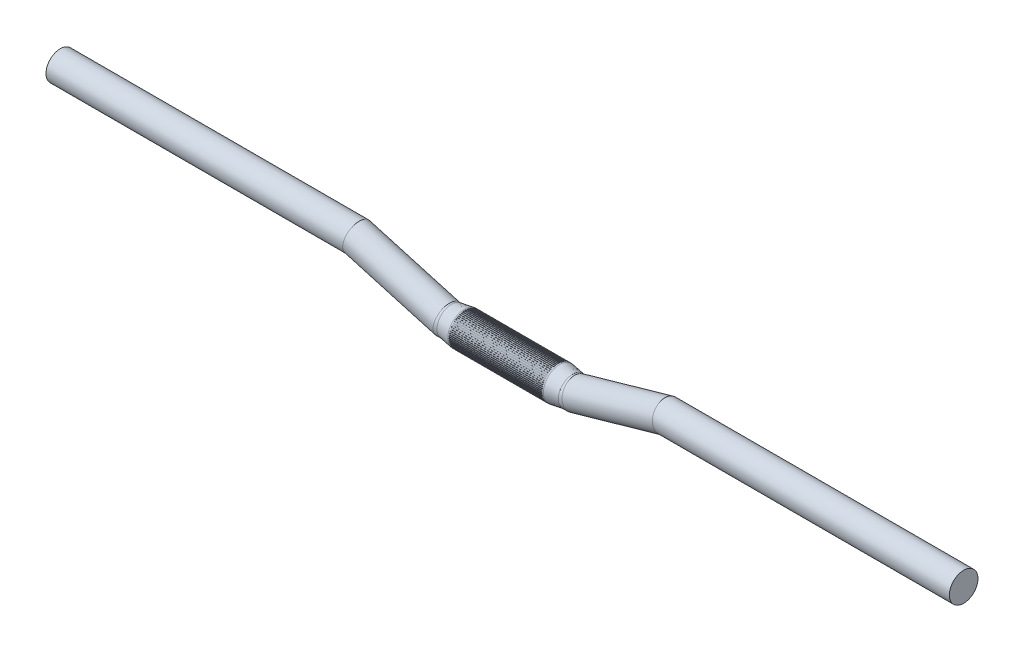
from build123d import *

# Parameters (mm, degrees)
ESQUISSE2_R                  = 11.1
ESQUISSE4_R                  = 12.7
BOSS_EXTRU_1_DEPTH           = 47
ESQUISSE5_W                  = 0.5
ESQUISSE5_H                  = 0.5
ENL_V_MAT_EXTRU_1_DEPTH      = 36
R_P_TITION_CIRCULAIRE1_COUNT = 68
SYM_TRIE1_COPY_1_SKETCH_W    = 0.5
SYM_TRIE1_COPY_1_SKETCH_H    = 0.5
SYM_TRIE1_COPY_1_DEPTH       = 36
SYM_TRIE1_COPY_2_SKETCH_W    = 0.5
SYM_TRIE1_COPY_2_SKETCH_H    = 0.5
SYM_TRIE1_COPY_2_DEPTH       = 36
SYM_TRIE1_COPY_3_SKETCH_W    = 0.5
SYM_TRIE1_COPY_3_SKETCH_H    = 0.5
SYM_TRIE1_COPY_3_DEPTH       = 36
SYM_TRIE1_COPY_4_SKETCH_W    = 0.5
SYM_TRIE1_COPY_4_SKETCH_H    = 0.5
SYM_TRIE1_COPY_4_DEPTH       = 36
SYM_TRIE1_COPY_5_SKETCH_W    = 0.5
SYM_TRIE1_COPY_5_SKETCH_H    = 0.5
SYM_TRIE1_COPY_5_DEPTH       = 36
SYM_TRIE1_COPY_6_SKETCH_W    = 0.5
SYM_TRIE1_COPY_6_SKETCH_H    = 0.5
SYM_TRIE1_COPY_6_DEPTH       = 36
SYM_TRIE1_COPY_7_SKETCH_W    = 0.5
SYM_TRIE1_COPY_7_SKETCH_H    = 0.5
SYM_TRIE1_COPY_7_DEPTH       = 36
SYM_TRIE1_COPY_8_SKETCH_W    = 0.5
SYM_TRIE1_COPY_8_SKETCH_H    = 0.5
SYM_TRIE1_COPY_8_DEPTH       = 36
SYM_TRIE1_COPY_9_SKETCH_W    = 0.5
SYM_TRIE1_COPY_9_SKETCH_H    = 0.5
SYM_TRIE1_COPY_9_DEPTH       = 36
SYM_TRIE1_COPY_10_SKETCH_W   = 0.5
SYM_TRIE1_COPY_10_SKETCH_H   = 0.5
SYM_TRIE1_COPY_10_DEPTH      = 36
SYM_TRIE1_COPY_11_SKETCH_W   = 0.5
SYM_TRIE1_COPY_11_SKETCH_H   = 0.5
SYM_TRIE1_COPY_11_DEPTH      = 36
SYM_TRIE1_COPY_12_SKETCH_W   = 0.5
SYM_TRIE1_COPY_12_SKETCH_H   = 0.5
SYM_TRIE1_COPY_12_DEPTH      = 36
SYM_TRIE1_COPY_13_SKETCH_W   = 0.5
SYM_TRIE1_COPY_13_SKETCH_H   = 0.5
SYM_TRIE1_COPY_13_DEPTH      = 36
SYM_TRIE1_COPY_14_SKETCH_W   = 0.5
SYM_TRIE1_COPY_14_SKETCH_H   = 0.5
SYM_TRIE1_COPY_14_DEPTH      = 36
SYM_TRIE1_COPY_15_SKETCH_W   = 0.5
SYM_TRIE1_COPY_15_SKETCH_H   = 0.5
SYM_TRIE1_COPY_15_DEPTH      = 36
SYM_TRIE1_COPY_16_SKETCH_W   = 0.5
SYM_TRIE1_COPY_16_SKETCH_H   = 0.5
SYM_TRIE1_COPY_16_DEPTH      = 36
SYM_TRIE1_COPY_17_SKETCH_W   = 0.5
SYM_TRIE1_COPY_17_SKETCH_H   = 0.5
SYM_TRIE1_COPY_17_DEPTH      = 36
SYM_TRIE1_COPY_18_SKETCH_W   = 0.5
SYM_TRIE1_COPY_18_SKETCH_H   = 0.5
SYM_TRIE1_COPY_18_DEPTH      = 36
SYM_TRIE1_COPY_19_SKETCH_W   = 0.5
SYM_TRIE1_COPY_19_SKETCH_H   = 0.5
SYM_TRIE1_COPY_19_DEPTH      = 36
SYM_TRIE1_COPY_20_SKETCH_W   = 0.5
SYM_TRIE1_COPY_20_SKETCH_H   = 0.5
SYM_TRIE1_COPY_20_DEPTH      = 36
SYM_TRIE1_COPY_21_SKETCH_W   = 0.5
SYM_TRIE1_COPY_21_SKETCH_H   = 0.5
SYM_TRIE1_COPY_21_DEPTH      = 36
SYM_TRIE1_COPY_22_SKETCH_W   = 0.5
SYM_TRIE1_COPY_22_SKETCH_H   = 0.5
SYM_TRIE1_COPY_22_DEPTH      = 36
SYM_TRIE1_COPY_23_SKETCH_W   = 0.5
SYM_TRIE1_COPY_23_SKETCH_H   = 0.5
SYM_TRIE1_COPY_23_DEPTH      = 36
SYM_TRIE1_COPY_24_SKETCH_W   = 0.5
SYM_TRIE1_COPY_24_SKETCH_H   = 0.5
SYM_TRIE1_COPY_24_DEPTH      = 36
SYM_TRIE1_COPY_25_SKETCH_W   = 0.5
SYM_TRIE1_COPY_25_SKETCH_H   = 0.5
SYM_TRIE1_COPY_25_DEPTH      = 36
SYM_TRIE1_COPY_26_SKETCH_W   = 0.5
SYM_TRIE1_COPY_26_SKETCH_H   = 0.5
SYM_TRIE1_COPY_26_DEPTH      = 36
SYM_TRIE1_COPY_27_SKETCH_W   = 0.5
SYM_TRIE1_COPY_27_SKETCH_H   = 0.5
SYM_TRIE1_COPY_27_DEPTH      = 36
SYM_TRIE1_COPY_28_SKETCH_W   = 0.5
SYM_TRIE1_COPY_28_SKETCH_H   = 0.5
SYM_TRIE1_COPY_28_DEPTH      = 36
SYM_TRIE1_COPY_29_SKETCH_W   = 0.5
SYM_TRIE1_COPY_29_SKETCH_H   = 0.5
SYM_TRIE1_COPY_29_DEPTH      = 36
SYM_TRIE1_COPY_30_SKETCH_W   = 0.5
SYM_TRIE1_COPY_30_SKETCH_H   = 0.5
SYM_TRIE1_COPY_30_DEPTH      = 36
SYM_TRIE1_COPY_31_SKETCH_W   = 0.5
SYM_TRIE1_COPY_31_SKETCH_H   = 0.5
SYM_TRIE1_COPY_31_DEPTH      = 36
SYM_TRIE1_COPY_32_SKETCH_W   = 0.5
SYM_TRIE1_COPY_32_SKETCH_H   = 0.5
SYM_TRIE1_COPY_32_DEPTH      = 36
SYM_TRIE1_COPY_33_SKETCH_W   = 0.5
SYM_TRIE1_COPY_33_SKETCH_H   = 0.5
SYM_TRIE1_COPY_33_DEPTH      = 36
SYM_TRIE1_COPY_34_SKETCH_W   = 0.5
SYM_TRIE1_COPY_34_SKETCH_H   = 0.5
SYM_TRIE1_COPY_34_DEPTH      = 36
SYM_TRIE1_COPY_35_SKETCH_W   = 0.5
SYM_TRIE1_COPY_35_SKETCH_H   = 0.5
SYM_TRIE1_COPY_35_DEPTH      = 36
SYM_TRIE1_COPY_36_SKETCH_W   = 0.5
SYM_TRIE1_COPY_36_SKETCH_H   = 0.5
SYM_TRIE1_COPY_36_DEPTH      = 36
SYM_TRIE1_COPY_37_SKETCH_W   = 0.5
SYM_TRIE1_COPY_37_SKETCH_H   = 0.5
SYM_TRIE1_COPY_37_DEPTH      = 36
SYM_TRIE1_COPY_38_SKETCH_W   = 0.5
SYM_TRIE1_COPY_38_SKETCH_H   = 0.5
SYM_TRIE1_COPY_38_DEPTH      = 36
SYM_TRIE1_COPY_39_SKETCH_W   = 0.5
SYM_TRIE1_COPY_39_SKETCH_H   = 0.5
SYM_TRIE1_COPY_39_DEPTH      = 36
SYM_TRIE1_COPY_40_SKETCH_W   = 0.5
SYM_TRIE1_COPY_40_SKETCH_H   = 0.5
SYM_TRIE1_COPY_40_DEPTH      = 36
SYM_TRIE1_COPY_41_SKETCH_W   = 0.5
SYM_TRIE1_COPY_41_SKETCH_H   = 0.5
SYM_TRIE1_COPY_41_DEPTH      = 36
SYM_TRIE1_COPY_42_SKETCH_W   = 0.5
SYM_TRIE1_COPY_42_SKETCH_H   = 0.5
SYM_TRIE1_COPY_42_DEPTH      = 36
SYM_TRIE1_COPY_43_SKETCH_W   = 0.5
SYM_TRIE1_COPY_43_SKETCH_H   = 0.5
SYM_TRIE1_COPY_43_DEPTH      = 36
SYM_TRIE1_COPY_44_SKETCH_W   = 0.5
SYM_TRIE1_COPY_44_SKETCH_H   = 0.5
SYM_TRIE1_COPY_44_DEPTH      = 36
SYM_TRIE1_COPY_45_SKETCH_W   = 0.5
SYM_TRIE1_COPY_45_SKETCH_H   = 0.5
SYM_TRIE1_COPY_45_DEPTH      = 36
SYM_TRIE1_COPY_46_SKETCH_W   = 0.5
SYM_TRIE1_COPY_46_SKETCH_H   = 0.5
SYM_TRIE1_COPY_46_DEPTH      = 36
SYM_TRIE1_COPY_47_SKETCH_W   = 0.5
SYM_TRIE1_COPY_47_SKETCH_H   = 0.5
SYM_TRIE1_COPY_47_DEPTH      = 36
SYM_TRIE1_COPY_48_SKETCH_W   = 0.5
SYM_TRIE1_COPY_48_SKETCH_H   = 0.5
SYM_TRIE1_COPY_48_DEPTH      = 36
SYM_TRIE1_COPY_49_SKETCH_W   = 0.5
SYM_TRIE1_COPY_49_SKETCH_H   = 0.5
SYM_TRIE1_COPY_49_DEPTH      = 36
SYM_TRIE1_COPY_50_SKETCH_W   = 0.5
SYM_TRIE1_COPY_50_SKETCH_H   = 0.5
SYM_TRIE1_COPY_50_DEPTH      = 36
SYM_TRIE1_COPY_51_SKETCH_W   = 0.5
SYM_TRIE1_COPY_51_SKETCH_H   = 0.5
SYM_TRIE1_COPY_51_DEPTH      = 36
SYM_TRIE1_COPY_52_SKETCH_W   = 0.5
SYM_TRIE1_COPY_52_SKETCH_H   = 0.5
SYM_TRIE1_COPY_52_DEPTH      = 36
SYM_TRIE1_COPY_53_SKETCH_W   = 0.5
SYM_TRIE1_COPY_53_SKETCH_H   = 0.5
SYM_TRIE1_COPY_53_DEPTH      = 36
SYM_TRIE1_COPY_54_SKETCH_W   = 0.5
SYM_TRIE1_COPY_54_SKETCH_H   = 0.5
SYM_TRIE1_COPY_54_DEPTH      = 36
SYM_TRIE1_COPY_55_SKETCH_W   = 0.5
SYM_TRIE1_COPY_55_SKETCH_H   = 0.5
SYM_TRIE1_COPY_55_DEPTH      = 36
SYM_TRIE1_COPY_56_SKETCH_W   = 0.5
SYM_TRIE1_COPY_56_SKETCH_H   = 0.5
SYM_TRIE1_COPY_56_DEPTH      = 36
SYM_TRIE1_COPY_57_SKETCH_W   = 0.5
SYM_TRIE1_COPY_57_SKETCH_H   = 0.5
SYM_TRIE1_COPY_57_DEPTH      = 36
SYM_TRIE1_COPY_58_SKETCH_W   = 0.5
SYM_TRIE1_COPY_58_SKETCH_H   = 0.5
SYM_TRIE1_COPY_58_DEPTH      = 36
SYM_TRIE1_COPY_59_SKETCH_W   = 0.5
SYM_TRIE1_COPY_59_SKETCH_H   = 0.5
SYM_TRIE1_COPY_59_DEPTH      = 36
SYM_TRIE1_COPY_60_SKETCH_W   = 0.5
SYM_TRIE1_COPY_60_SKETCH_H   = 0.5
SYM_TRIE1_COPY_60_DEPTH      = 36
SYM_TRIE1_COPY_61_SKETCH_W   = 0.5
SYM_TRIE1_COPY_61_SKETCH_H   = 0.5
SYM_TRIE1_COPY_61_DEPTH      = 36
SYM_TRIE1_COPY_62_SKETCH_W   = 0.5
SYM_TRIE1_COPY_62_SKETCH_H   = 0.5
SYM_TRIE1_COPY_62_DEPTH      = 36
SYM_TRIE1_COPY_63_SKETCH_W   = 0.5
SYM_TRIE1_COPY_63_SKETCH_H   = 0.5
SYM_TRIE1_COPY_63_DEPTH      = 36
SYM_TRIE1_COPY_64_SKETCH_W   = 0.5
SYM_TRIE1_COPY_64_SKETCH_H   = 0.5
SYM_TRIE1_COPY_64_DEPTH      = 36
SYM_TRIE1_COPY_65_SKETCH_W   = 0.5
SYM_TRIE1_COPY_65_SKETCH_H   = 0.5
SYM_TRIE1_COPY_65_DEPTH      = 36
SYM_TRIE1_COPY_66_SKETCH_W   = 0.5
SYM_TRIE1_COPY_66_SKETCH_H   = 0.5
SYM_TRIE1_COPY_66_DEPTH      = 36
SYM_TRIE1_COPY_67_SKETCH_W   = 0.5
SYM_TRIE1_COPY_67_SKETCH_H   = 0.5
SYM_TRIE1_COPY_67_DEPTH      = 36
CHANFREIN3_SIZE2             = 1.583844403
CHANFREIN3_SIZE              = 10


with BuildPart() as part:
    # Balayage1: sweep along a path in Esquisse1
    with BuildLine(Plane.XY) as balayage1_path:
        Line((0, 0), (50, 0))
        Line((50, 0), (120, 20))
        Line((120, 20), (350, 20))
    # Esquisse2 → Balayage1 (sweep)
    with BuildSketch(Plane(origin=(0, 0, 0), x_dir=(0, 0, -1), z_dir=(1, 0, 0))):
        Circle(ESQUISSE2_R)
    balayage1 = sweep(path=balayage1_path.line, transition=Transition.RIGHT)

    # Esquisse4 → Boss.-Extru.1 (add)
    with BuildSketch(Plane.ZY):
        Circle(ESQUISSE4_R)
    boss_extru_1 = extrude(amount=-BOSS_EXTRU_1_DEPTH)

    # Esquisse5 → Enlèv. mat.-Extru.1 (cut)
    with BuildSketch(Plane.ZY):
        with Locations((12.7, 0)):
            Rectangle(ESQUISSE5_W, ESQUISSE5_H)
    enl_v_mat_extru_1 = extrude(amount=-ENL_V_MAT_EXTRU_1_DEPTH, mode=Mode.SUBTRACT)

    # Répétition circulaire1: Enlèv. mat.-Extru.1 ×68 about axis
    r_p_tition_circulaire1_axis = Axis((0, 0, 0), (-1, 0, 0))
    for i in range(1, R_P_TITION_CIRCULAIRE1_COUNT):
        add(enl_v_mat_extru_1.rotate(r_p_tition_circulaire1_axis, i * 360 / R_P_TITION_CIRCULAIRE1_COUNT), mode=Mode.SUBTRACT)

    # Symétrie1: Balayage1, Boss.-Extru.1, Enlèv. mat.-Extru.1 across Right Plane
    add(balayage1.mirror(Plane(origin=(0, 0, 0), x_dir=(0, 0, -1), z_dir=(1, 0, 0))))
    add(boss_extru_1.mirror(Plane(origin=(0, 0, 0), x_dir=(0, 0, -1), z_dir=(1, 0, 0))))
    add(enl_v_mat_extru_1.mirror(Plane(origin=(0, 0, 0), x_dir=(0, 0, -1), z_dir=(1, 0, 0))), mode=Mode.SUBTRACT)

    # Symétrie1 copy 1 sketch → Symétrie1 copy 1 (cut)
    with BuildSketch(Plane(origin=(0, 0, 0), x_dir=(0, 0.09226835946330199, 0.9957341762950345), z_dir=(1, 0, 0))):
        with Locations((12.7, 0)):
            Rectangle(SYM_TRIE1_COPY_1_SKETCH_W, SYM_TRIE1_COPY_1_SKETCH_H)
    extrude(amount=-SYM_TRIE1_COPY_1_DEPTH, mode=Mode.SUBTRACT)

    # Symétrie1 copy 2 sketch → Symétrie1 copy 2 (cut)
    with BuildSketch(Plane(origin=(0, 0, 0), x_dir=(0, 0.18374951781657034, 0.9829730996839018), z_dir=(1, 0, 0))):
        with Locations((12.7, 0)):
            Rectangle(SYM_TRIE1_COPY_2_SKETCH_W, SYM_TRIE1_COPY_2_SKETCH_H)
    extrude(amount=-SYM_TRIE1_COPY_2_DEPTH, mode=Mode.SUBTRACT)

    # Symétrie1 copy 3 sketch → Symétrie1 copy 3 (cut)
    with BuildSketch(Plane(origin=(0, 0, 0), x_dir=(0, 0.27366299007208283, 0.961825643172819), z_dir=(1, 0, 0))):
        with Locations((12.7, 0)):
            Rectangle(SYM_TRIE1_COPY_3_SKETCH_W, SYM_TRIE1_COPY_3_SKETCH_H)
    extrude(amount=-SYM_TRIE1_COPY_3_DEPTH, mode=Mode.SUBTRACT)

    # Symétrie1 copy 4 sketch → Symétrie1 copy 4 (cut)
    with BuildSketch(Plane(origin=(0, 0, 0), x_dir=(0, 0.3612416661871529, 0.9324722294043558), z_dir=(1, 0, 0))):
        with Locations((12.7, 0)):
            Rectangle(SYM_TRIE1_COPY_4_SKETCH_W, SYM_TRIE1_COPY_4_SKETCH_H)
    extrude(amount=-SYM_TRIE1_COPY_4_DEPTH, mode=Mode.SUBTRACT)

    # Symétrie1 copy 5 sketch → Symétrie1 copy 5 (cut)
    with BuildSketch(Plane(origin=(0, 0, 0), x_dir=(0, 0.4457383557765382, 0.8951632913550623), z_dir=(1, 0, 0))):
        with Locations((12.7, 0)):
            Rectangle(SYM_TRIE1_COPY_5_SKETCH_W, SYM_TRIE1_COPY_5_SKETCH_H)
    extrude(amount=-SYM_TRIE1_COPY_5_DEPTH, mode=Mode.SUBTRACT)

    # Symétrie1 copy 6 sketch → Symétrie1 copy 6 (cut)
    with BuildSketch(Plane(origin=(0, 0, 0), x_dir=(0, 0.5264321628773557, 0.8502171357296142), z_dir=(1, 0, 0))):
        with Locations((12.7, 0)):
            Rectangle(SYM_TRIE1_COPY_6_SKETCH_W, SYM_TRIE1_COPY_6_SKETCH_H)
    extrude(amount=-SYM_TRIE1_COPY_6_DEPTH, mode=Mode.SUBTRACT)

    # Symétrie1 copy 7 sketch → Symétrie1 copy 7 (cut)
    with BuildSketch(Plane(origin=(0, 0, 0), x_dir=(0, 0.6026346363792563, 0.7980172272802396), z_dir=(1, 0, 0))):
        with Locations((12.7, 0)):
            Rectangle(SYM_TRIE1_COPY_7_SKETCH_W, SYM_TRIE1_COPY_7_SKETCH_H)
    extrude(amount=-SYM_TRIE1_COPY_7_DEPTH, mode=Mode.SUBTRACT)

    # Symétrie1 copy 8 sketch → Symétrie1 copy 8 (cut)
    with BuildSketch(Plane(origin=(0, 0, 0), x_dir=(0, 0.6736956436465572, 0.7390089172206591), z_dir=(1, 0, 0))):
        with Locations((12.7, 0)):
            Rectangle(SYM_TRIE1_COPY_8_SKETCH_W, SYM_TRIE1_COPY_8_SKETCH_H)
    extrude(amount=-SYM_TRIE1_COPY_8_DEPTH, mode=Mode.SUBTRACT)

    # Symétrie1 copy 9 sketch → Symétrie1 copy 9 (cut)
    with BuildSketch(Plane(origin=(0, 0, 0), x_dir=(0, 0.7390089172206592, 0.6736956436465572), z_dir=(1, 0, 0))):
        with Locations((12.7, 0)):
            Rectangle(SYM_TRIE1_COPY_9_SKETCH_W, SYM_TRIE1_COPY_9_SKETCH_H)
    extrude(amount=-SYM_TRIE1_COPY_9_DEPTH, mode=Mode.SUBTRACT)

    # Symétrie1 copy 10 sketch → Symétrie1 copy 10 (cut)
    with BuildSketch(Plane(origin=(0, 0, 0), x_dir=(0, 0.7980172272802395, 0.6026346363792565), z_dir=(1, 0, 0))):
        with Locations((12.7, 0)):
            Rectangle(SYM_TRIE1_COPY_10_SKETCH_W, SYM_TRIE1_COPY_10_SKETCH_H)
    extrude(amount=-SYM_TRIE1_COPY_10_DEPTH, mode=Mode.SUBTRACT)

    # Symétrie1 copy 11 sketch → Symétrie1 copy 11 (cut)
    with BuildSketch(Plane(origin=(0, 0, 0), x_dir=(0, 0.8502171357296141, 0.5264321628773558), z_dir=(1, 0, 0))):
        with Locations((12.7, 0)):
            Rectangle(SYM_TRIE1_COPY_11_SKETCH_W, SYM_TRIE1_COPY_11_SKETCH_H)
    extrude(amount=-SYM_TRIE1_COPY_11_DEPTH, mode=Mode.SUBTRACT)

    # Symétrie1 copy 12 sketch → Symétrie1 copy 12 (cut)
    with BuildSketch(Plane(origin=(0, 0, 0), x_dir=(0, 0.8951632913550623, 0.4457383557765383), z_dir=(1, 0, 0))):
        with Locations((12.7, 0)):
            Rectangle(SYM_TRIE1_COPY_12_SKETCH_W, SYM_TRIE1_COPY_12_SKETCH_H)
    extrude(amount=-SYM_TRIE1_COPY_12_DEPTH, mode=Mode.SUBTRACT)

    # Symétrie1 copy 13 sketch → Symétrie1 copy 13 (cut)
    with BuildSketch(Plane(origin=(0, 0, 0), x_dir=(0, 0.9324722294043558, 0.36124166618715287), z_dir=(1, 0, 0))):
        with Locations((12.7, 0)):
            Rectangle(SYM_TRIE1_COPY_13_SKETCH_W, SYM_TRIE1_COPY_13_SKETCH_H)
    extrude(amount=-SYM_TRIE1_COPY_13_DEPTH, mode=Mode.SUBTRACT)

    # Symétrie1 copy 14 sketch → Symétrie1 copy 14 (cut)
    with BuildSketch(Plane(origin=(0, 0, 0), x_dir=(0, 0.961825643172819, 0.273662990072083), z_dir=(1, 0, 0))):
        with Locations((12.7, 0)):
            Rectangle(SYM_TRIE1_COPY_14_SKETCH_W, SYM_TRIE1_COPY_14_SKETCH_H)
    extrude(amount=-SYM_TRIE1_COPY_14_DEPTH, mode=Mode.SUBTRACT)

    # Symétrie1 copy 15 sketch → Symétrie1 copy 15 (cut)
    with BuildSketch(Plane(origin=(0, 0, 0), x_dir=(0, 0.9829730996839018, 0.18374951781657053), z_dir=(1, 0, 0))):
        with Locations((12.7, 0)):
            Rectangle(SYM_TRIE1_COPY_15_SKETCH_W, SYM_TRIE1_COPY_15_SKETCH_H)
    extrude(amount=-SYM_TRIE1_COPY_15_DEPTH, mode=Mode.SUBTRACT)

    # Symétrie1 copy 16 sketch → Symétrie1 copy 16 (cut)
    with BuildSketch(Plane(origin=(0, 0, 0), x_dir=(0, 0.9957341762950345, 0.09226835946330202), z_dir=(1, 0, 0))):
        with Locations((12.7, 0)):
            Rectangle(SYM_TRIE1_COPY_16_SKETCH_W, SYM_TRIE1_COPY_16_SKETCH_H)
    extrude(amount=-SYM_TRIE1_COPY_16_DEPTH, mode=Mode.SUBTRACT)

    # Symétrie1 copy 17 sketch → Symétrie1 copy 17 (cut)
    with BuildSketch(Plane.YZ):
        with Locations((12.7, 0)):
            Rectangle(SYM_TRIE1_COPY_17_SKETCH_W, SYM_TRIE1_COPY_17_SKETCH_H)
    extrude(amount=-SYM_TRIE1_COPY_17_DEPTH, mode=Mode.SUBTRACT)

    # Symétrie1 copy 18 sketch → Symétrie1 copy 18 (cut)
    with BuildSketch(Plane(origin=(0, 0, 0), x_dir=(0, 0.9957341762950345, -0.09226835946330211), z_dir=(1, 0, 0))):
        with Locations((12.7, 0)):
            Rectangle(SYM_TRIE1_COPY_18_SKETCH_W, SYM_TRIE1_COPY_18_SKETCH_H)
    extrude(amount=-SYM_TRIE1_COPY_18_DEPTH, mode=Mode.SUBTRACT)

    # Symétrie1 copy 19 sketch → Symétrie1 copy 19 (cut)
    with BuildSketch(Plane(origin=(0, 0, 0), x_dir=(0, 0.9829730996839018, -0.18374951781657017), z_dir=(1, 0, 0))):
        with Locations((12.7, 0)):
            Rectangle(SYM_TRIE1_COPY_19_SKETCH_W, SYM_TRIE1_COPY_19_SKETCH_H)
    extrude(amount=-SYM_TRIE1_COPY_19_DEPTH, mode=Mode.SUBTRACT)

    # Symétrie1 copy 20 sketch → Symétrie1 copy 20 (cut)
    with BuildSketch(Plane(origin=(0, 0, 0), x_dir=(0, 0.9618256431728192, -0.27366299007208267), z_dir=(1, 0, 0))):
        with Locations((12.7, 0)):
            Rectangle(SYM_TRIE1_COPY_20_SKETCH_W, SYM_TRIE1_COPY_20_SKETCH_H)
    extrude(amount=-SYM_TRIE1_COPY_20_DEPTH, mode=Mode.SUBTRACT)

    # Symétrie1 copy 21 sketch → Symétrie1 copy 21 (cut)
    with BuildSketch(Plane(origin=(0, 0, 0), x_dir=(0, 0.9324722294043558, -0.3612416661871529), z_dir=(1, 0, 0))):
        with Locations((12.7, 0)):
            Rectangle(SYM_TRIE1_COPY_21_SKETCH_W, SYM_TRIE1_COPY_21_SKETCH_H)
    extrude(amount=-SYM_TRIE1_COPY_21_DEPTH, mode=Mode.SUBTRACT)

    # Symétrie1 copy 22 sketch → Symétrie1 copy 22 (cut)
    with BuildSketch(Plane(origin=(0, 0, 0), x_dir=(0, 0.8951632913550623, -0.4457383557765382), z_dir=(1, 0, 0))):
        with Locations((12.7, 0)):
            Rectangle(SYM_TRIE1_COPY_22_SKETCH_W, SYM_TRIE1_COPY_22_SKETCH_H)
    extrude(amount=-SYM_TRIE1_COPY_22_DEPTH, mode=Mode.SUBTRACT)

    # Symétrie1 copy 23 sketch → Symétrie1 copy 23 (cut)
    with BuildSketch(Plane(origin=(0, 0, 0), x_dir=(0, 0.8502171357296141, -0.526432162877356), z_dir=(1, 0, 0))):
        with Locations((12.7, 0)):
            Rectangle(SYM_TRIE1_COPY_23_SKETCH_W, SYM_TRIE1_COPY_23_SKETCH_H)
    extrude(amount=-SYM_TRIE1_COPY_23_DEPTH, mode=Mode.SUBTRACT)

    # Symétrie1 copy 24 sketch → Symétrie1 copy 24 (cut)
    with BuildSketch(Plane(origin=(0, 0, 0), x_dir=(0, 0.7980172272802396, -0.6026346363792563), z_dir=(1, 0, 0))):
        with Locations((12.7, 0)):
            Rectangle(SYM_TRIE1_COPY_24_SKETCH_W, SYM_TRIE1_COPY_24_SKETCH_H)
    extrude(amount=-SYM_TRIE1_COPY_24_DEPTH, mode=Mode.SUBTRACT)

    # Symétrie1 copy 25 sketch → Symétrie1 copy 25 (cut)
    with BuildSketch(Plane(origin=(0, 0, 0), x_dir=(0, 0.7390089172206594, -0.6736956436465569), z_dir=(1, 0, 0))):
        with Locations((12.7, 0)):
            Rectangle(SYM_TRIE1_COPY_25_SKETCH_W, SYM_TRIE1_COPY_25_SKETCH_H)
    extrude(amount=-SYM_TRIE1_COPY_25_DEPTH, mode=Mode.SUBTRACT)

    # Symétrie1 copy 26 sketch → Symétrie1 copy 26 (cut)
    with BuildSketch(Plane(origin=(0, 0, 0), x_dir=(0, 0.6736956436465571, -0.7390089172206593), z_dir=(1, 0, 0))):
        with Locations((12.7, 0)):
            Rectangle(SYM_TRIE1_COPY_26_SKETCH_W, SYM_TRIE1_COPY_26_SKETCH_H)
    extrude(amount=-SYM_TRIE1_COPY_26_DEPTH, mode=Mode.SUBTRACT)

    # Symétrie1 copy 27 sketch → Symétrie1 copy 27 (cut)
    with BuildSketch(Plane(origin=(0, 0, 0), x_dir=(0, 0.6026346363792564, -0.7980172272802395), z_dir=(1, 0, 0))):
        with Locations((12.7, 0)):
            Rectangle(SYM_TRIE1_COPY_27_SKETCH_W, SYM_TRIE1_COPY_27_SKETCH_H)
    extrude(amount=-SYM_TRIE1_COPY_27_DEPTH, mode=Mode.SUBTRACT)

    # Symétrie1 copy 28 sketch → Symétrie1 copy 28 (cut)
    with BuildSketch(Plane(origin=(0, 0, 0), x_dir=(0, 0.5264321628773561, -0.850217135729614), z_dir=(1, 0, 0))):
        with Locations((12.7, 0)):
            Rectangle(SYM_TRIE1_COPY_28_SKETCH_W, SYM_TRIE1_COPY_28_SKETCH_H)
    extrude(amount=-SYM_TRIE1_COPY_28_DEPTH, mode=Mode.SUBTRACT)

    # Symétrie1 copy 29 sketch → Symétrie1 copy 29 (cut)
    with BuildSketch(Plane(origin=(0, 0, 0), x_dir=(0, 0.44573835577653836, -0.8951632913550622), z_dir=(1, 0, 0))):
        with Locations((12.7, 0)):
            Rectangle(SYM_TRIE1_COPY_29_SKETCH_W, SYM_TRIE1_COPY_29_SKETCH_H)
    extrude(amount=-SYM_TRIE1_COPY_29_DEPTH, mode=Mode.SUBTRACT)

    # Symétrie1 copy 30 sketch → Symétrie1 copy 30 (cut)
    with BuildSketch(Plane(origin=(0, 0, 0), x_dir=(0, 0.3612416661871533, -0.9324722294043557), z_dir=(1, 0, 0))):
        with Locations((12.7, 0)):
            Rectangle(SYM_TRIE1_COPY_30_SKETCH_W, SYM_TRIE1_COPY_30_SKETCH_H)
    extrude(amount=-SYM_TRIE1_COPY_30_DEPTH, mode=Mode.SUBTRACT)

    # Symétrie1 copy 31 sketch → Symétrie1 copy 31 (cut)
    with BuildSketch(Plane(origin=(0, 0, 0), x_dir=(0, 0.27366299007208267, -0.9618256431728192), z_dir=(1, 0, 0))):
        with Locations((12.7, 0)):
            Rectangle(SYM_TRIE1_COPY_31_SKETCH_W, SYM_TRIE1_COPY_31_SKETCH_H)
    extrude(amount=-SYM_TRIE1_COPY_31_DEPTH, mode=Mode.SUBTRACT)

    # Symétrie1 copy 32 sketch → Symétrie1 copy 32 (cut)
    with BuildSketch(Plane(origin=(0, 0, 0), x_dir=(0, 0.18374951781657037, -0.9829730996839018), z_dir=(1, 0, 0))):
        with Locations((12.7, 0)):
            Rectangle(SYM_TRIE1_COPY_32_SKETCH_W, SYM_TRIE1_COPY_32_SKETCH_H)
    extrude(amount=-SYM_TRIE1_COPY_32_DEPTH, mode=Mode.SUBTRACT)

    # Symétrie1 copy 33 sketch → Symétrie1 copy 33 (cut)
    with BuildSketch(Plane(origin=(0, 0, 0), x_dir=(0, 0.0922683594633023, -0.9957341762950345), z_dir=(1, 0, 0))):
        with Locations((12.7, 0)):
            Rectangle(SYM_TRIE1_COPY_33_SKETCH_W, SYM_TRIE1_COPY_33_SKETCH_H)
    extrude(amount=-SYM_TRIE1_COPY_33_DEPTH, mode=Mode.SUBTRACT)

    # Symétrie1 copy 34 sketch → Symétrie1 copy 34 (cut)
    with BuildSketch(Plane(origin=(0, 0, 0), x_dir=(0, 0, -1), z_dir=(1, 0, 0))):
        with Locations((12.7, 0)):
            Rectangle(SYM_TRIE1_COPY_34_SKETCH_W, SYM_TRIE1_COPY_34_SKETCH_H)
    extrude(amount=-SYM_TRIE1_COPY_34_DEPTH, mode=Mode.SUBTRACT)

    # Symétrie1 copy 35 sketch → Symétrie1 copy 35 (cut)
    with BuildSketch(Plane(origin=(0, 0, 0), x_dir=(0, -0.09226835946330161, -0.9957341762950346), z_dir=(1, 0, 0))):
        with Locations((12.7, 0)):
            Rectangle(SYM_TRIE1_COPY_35_SKETCH_W, SYM_TRIE1_COPY_35_SKETCH_H)
    extrude(amount=-SYM_TRIE1_COPY_35_DEPTH, mode=Mode.SUBTRACT)

    # Symétrie1 copy 36 sketch → Symétrie1 copy 36 (cut)
    with BuildSketch(Plane(origin=(0, 0, 0), x_dir=(0, -0.18374951781657056, -0.9829730996839018), z_dir=(1, 0, 0))):
        with Locations((12.7, 0)):
            Rectangle(SYM_TRIE1_COPY_36_SKETCH_W, SYM_TRIE1_COPY_36_SKETCH_H)
    extrude(amount=-SYM_TRIE1_COPY_36_DEPTH, mode=Mode.SUBTRACT)

    # Symétrie1 copy 37 sketch → Symétrie1 copy 37 (cut)
    with BuildSketch(Plane(origin=(0, 0, 0), x_dir=(0, -0.27366299007208283, -0.961825643172819), z_dir=(1, 0, 0))):
        with Locations((12.7, 0)):
            Rectangle(SYM_TRIE1_COPY_37_SKETCH_W, SYM_TRIE1_COPY_37_SKETCH_H)
    extrude(amount=-SYM_TRIE1_COPY_37_DEPTH, mode=Mode.SUBTRACT)

    # Symétrie1 copy 38 sketch → Symétrie1 copy 38 (cut)
    with BuildSketch(Plane(origin=(0, 0, 0), x_dir=(0, -0.3612416661871527, -0.9324722294043559), z_dir=(1, 0, 0))):
        with Locations((12.7, 0)):
            Rectangle(SYM_TRIE1_COPY_38_SKETCH_W, SYM_TRIE1_COPY_38_SKETCH_H)
    extrude(amount=-SYM_TRIE1_COPY_38_DEPTH, mode=Mode.SUBTRACT)

    # Symétrie1 copy 39 sketch → Symétrie1 copy 39 (cut)
    with BuildSketch(Plane(origin=(0, 0, 0), x_dir=(0, -0.44573835577653814, -0.8951632913550623), z_dir=(1, 0, 0))):
        with Locations((12.7, 0)):
            Rectangle(SYM_TRIE1_COPY_39_SKETCH_W, SYM_TRIE1_COPY_39_SKETCH_H)
    extrude(amount=-SYM_TRIE1_COPY_39_DEPTH, mode=Mode.SUBTRACT)

    # Symétrie1 copy 40 sketch → Symétrie1 copy 40 (cut)
    with BuildSketch(Plane(origin=(0, 0, 0), x_dir=(0, -0.5264321628773555, -0.8502171357296143), z_dir=(1, 0, 0))):
        with Locations((12.7, 0)):
            Rectangle(SYM_TRIE1_COPY_40_SKETCH_W, SYM_TRIE1_COPY_40_SKETCH_H)
    extrude(amount=-SYM_TRIE1_COPY_40_DEPTH, mode=Mode.SUBTRACT)

    # Symétrie1 copy 41 sketch → Symétrie1 copy 41 (cut)
    with BuildSketch(Plane(origin=(0, 0, 0), x_dir=(0, -0.6026346363792562, -0.7980172272802396), z_dir=(1, 0, 0))):
        with Locations((12.7, 0)):
            Rectangle(SYM_TRIE1_COPY_41_SKETCH_W, SYM_TRIE1_COPY_41_SKETCH_H)
    extrude(amount=-SYM_TRIE1_COPY_41_DEPTH, mode=Mode.SUBTRACT)

    # Symétrie1 copy 42 sketch → Symétrie1 copy 42 (cut)
    with BuildSketch(Plane(origin=(0, 0, 0), x_dir=(0, -0.6736956436465572, -0.7390089172206591), z_dir=(1, 0, 0))):
        with Locations((12.7, 0)):
            Rectangle(SYM_TRIE1_COPY_42_SKETCH_W, SYM_TRIE1_COPY_42_SKETCH_H)
    extrude(amount=-SYM_TRIE1_COPY_42_DEPTH, mode=Mode.SUBTRACT)

    # Symétrie1 copy 43 sketch → Symétrie1 copy 43 (cut)
    with BuildSketch(Plane(origin=(0, 0, 0), x_dir=(0, -0.739008917220659, -0.6736956436465574), z_dir=(1, 0, 0))):
        with Locations((12.7, 0)):
            Rectangle(SYM_TRIE1_COPY_43_SKETCH_W, SYM_TRIE1_COPY_43_SKETCH_H)
    extrude(amount=-SYM_TRIE1_COPY_43_DEPTH, mode=Mode.SUBTRACT)

    # Symétrie1 copy 44 sketch → Symétrie1 copy 44 (cut)
    with BuildSketch(Plane(origin=(0, 0, 0), x_dir=(0, -0.7980172272802395, -0.6026346363792565), z_dir=(1, 0, 0))):
        with Locations((12.7, 0)):
            Rectangle(SYM_TRIE1_COPY_44_SKETCH_W, SYM_TRIE1_COPY_44_SKETCH_H)
    extrude(amount=-SYM_TRIE1_COPY_44_DEPTH, mode=Mode.SUBTRACT)

    # Symétrie1 copy 45 sketch → Symétrie1 copy 45 (cut)
    with BuildSketch(Plane(origin=(0, 0, 0), x_dir=(0, -0.850217135729614, -0.5264321628773562), z_dir=(1, 0, 0))):
        with Locations((12.7, 0)):
            Rectangle(SYM_TRIE1_COPY_45_SKETCH_W, SYM_TRIE1_COPY_45_SKETCH_H)
    extrude(amount=-SYM_TRIE1_COPY_45_DEPTH, mode=Mode.SUBTRACT)

    # Symétrie1 copy 46 sketch → Symétrie1 copy 46 (cut)
    with BuildSketch(Plane(origin=(0, 0, 0), x_dir=(0, -0.8951632913550625, -0.44573835577653803), z_dir=(1, 0, 0))):
        with Locations((12.7, 0)):
            Rectangle(SYM_TRIE1_COPY_46_SKETCH_W, SYM_TRIE1_COPY_46_SKETCH_H)
    extrude(amount=-SYM_TRIE1_COPY_46_DEPTH, mode=Mode.SUBTRACT)

    # Symétrie1 copy 47 sketch → Symétrie1 copy 47 (cut)
    with BuildSketch(Plane(origin=(0, 0, 0), x_dir=(0, -0.9324722294043558, -0.361241666187153), z_dir=(1, 0, 0))):
        with Locations((12.7, 0)):
            Rectangle(SYM_TRIE1_COPY_47_SKETCH_W, SYM_TRIE1_COPY_47_SKETCH_H)
    extrude(amount=-SYM_TRIE1_COPY_47_DEPTH, mode=Mode.SUBTRACT)

    # Symétrie1 copy 48 sketch → Symétrie1 copy 48 (cut)
    with BuildSketch(Plane(origin=(0, 0, 0), x_dir=(0, -0.961825643172819, -0.2736629900720831), z_dir=(1, 0, 0))):
        with Locations((12.7, 0)):
            Rectangle(SYM_TRIE1_COPY_48_SKETCH_W, SYM_TRIE1_COPY_48_SKETCH_H)
    extrude(amount=-SYM_TRIE1_COPY_48_DEPTH, mode=Mode.SUBTRACT)

    # Symétrie1 copy 49 sketch → Symétrie1 copy 49 (cut)
    with BuildSketch(Plane(origin=(0, 0, 0), x_dir=(0, -0.9829730996839017, -0.18374951781657087), z_dir=(1, 0, 0))):
        with Locations((12.7, 0)):
            Rectangle(SYM_TRIE1_COPY_49_SKETCH_W, SYM_TRIE1_COPY_49_SKETCH_H)
    extrude(amount=-SYM_TRIE1_COPY_49_DEPTH, mode=Mode.SUBTRACT)

    # Symétrie1 copy 50 sketch → Symétrie1 copy 50 (cut)
    with BuildSketch(Plane(origin=(0, 0, 0), x_dir=(0, -0.9957341762950345, -0.0922683594633028), z_dir=(1, 0, 0))):
        with Locations((12.7, 0)):
            Rectangle(SYM_TRIE1_COPY_50_SKETCH_W, SYM_TRIE1_COPY_50_SKETCH_H)
    extrude(amount=-SYM_TRIE1_COPY_50_DEPTH, mode=Mode.SUBTRACT)

    # Symétrie1 copy 51 sketch → Symétrie1 copy 51 (cut)
    with BuildSketch(Plane(origin=(0, 0, 0), x_dir=(0, -1, 0), z_dir=(1, 0, 0))):
        with Locations((12.7, 0)):
            Rectangle(SYM_TRIE1_COPY_51_SKETCH_W, SYM_TRIE1_COPY_51_SKETCH_H)
    extrude(amount=-SYM_TRIE1_COPY_51_DEPTH, mode=Mode.SUBTRACT)

    # Symétrie1 copy 52 sketch → Symétrie1 copy 52 (cut)
    with BuildSketch(Plane(origin=(0, 0, 0), x_dir=(0, -0.9957341762950345, 0.09226835946330243), z_dir=(1, 0, 0))):
        with Locations((12.7, 0)):
            Rectangle(SYM_TRIE1_COPY_52_SKETCH_W, SYM_TRIE1_COPY_52_SKETCH_H)
    extrude(amount=-SYM_TRIE1_COPY_52_DEPTH, mode=Mode.SUBTRACT)

    # Symétrie1 copy 53 sketch → Symétrie1 copy 53 (cut)
    with BuildSketch(Plane(origin=(0, 0, 0), x_dir=(0, -0.9829730996839019, 0.18374951781656962), z_dir=(1, 0, 0))):
        with Locations((12.7, 0)):
            Rectangle(SYM_TRIE1_COPY_53_SKETCH_W, SYM_TRIE1_COPY_53_SKETCH_H)
    extrude(amount=-SYM_TRIE1_COPY_53_DEPTH, mode=Mode.SUBTRACT)

    # Symétrie1 copy 54 sketch → Symétrie1 copy 54 (cut)
    with BuildSketch(Plane(origin=(0, 0, 0), x_dir=(0, -0.961825643172819, 0.2736629900720828), z_dir=(1, 0, 0))):
        with Locations((12.7, 0)):
            Rectangle(SYM_TRIE1_COPY_54_SKETCH_W, SYM_TRIE1_COPY_54_SKETCH_H)
    extrude(amount=-SYM_TRIE1_COPY_54_DEPTH, mode=Mode.SUBTRACT)

    # Symétrie1 copy 55 sketch → Symétrie1 copy 55 (cut)
    with BuildSketch(Plane(origin=(0, 0, 0), x_dir=(0, -0.9324722294043559, 0.36124166618715264), z_dir=(1, 0, 0))):
        with Locations((12.7, 0)):
            Rectangle(SYM_TRIE1_COPY_55_SKETCH_W, SYM_TRIE1_COPY_55_SKETCH_H)
    extrude(amount=-SYM_TRIE1_COPY_55_DEPTH, mode=Mode.SUBTRACT)

    # Symétrie1 copy 56 sketch → Symétrie1 copy 56 (cut)
    with BuildSketch(Plane(origin=(0, 0, 0), x_dir=(0, -0.8951632913550626, 0.4457383557765377), z_dir=(1, 0, 0))):
        with Locations((12.7, 0)):
            Rectangle(SYM_TRIE1_COPY_56_SKETCH_W, SYM_TRIE1_COPY_56_SKETCH_H)
    extrude(amount=-SYM_TRIE1_COPY_56_DEPTH, mode=Mode.SUBTRACT)

    # Symétrie1 copy 57 sketch → Symétrie1 copy 57 (cut)
    with BuildSketch(Plane(origin=(0, 0, 0), x_dir=(0, -0.8502171357296141, 0.5264321628773558), z_dir=(1, 0, 0))):
        with Locations((12.7, 0)):
            Rectangle(SYM_TRIE1_COPY_57_SKETCH_W, SYM_TRIE1_COPY_57_SKETCH_H)
    extrude(amount=-SYM_TRIE1_COPY_57_DEPTH, mode=Mode.SUBTRACT)

    # Symétrie1 copy 58 sketch → Symétrie1 copy 58 (cut)
    with BuildSketch(Plane(origin=(0, 0, 0), x_dir=(0, -0.7980172272802397, 0.6026346363792562), z_dir=(1, 0, 0))):
        with Locations((12.7, 0)):
            Rectangle(SYM_TRIE1_COPY_58_SKETCH_W, SYM_TRIE1_COPY_58_SKETCH_H)
    extrude(amount=-SYM_TRIE1_COPY_58_DEPTH, mode=Mode.SUBTRACT)

    # Symétrie1 copy 59 sketch → Symétrie1 copy 59 (cut)
    with BuildSketch(Plane(origin=(0, 0, 0), x_dir=(0, -0.7390089172206594, 0.6736956436465569), z_dir=(1, 0, 0))):
        with Locations((12.7, 0)):
            Rectangle(SYM_TRIE1_COPY_59_SKETCH_W, SYM_TRIE1_COPY_59_SKETCH_H)
    extrude(amount=-SYM_TRIE1_COPY_59_DEPTH, mode=Mode.SUBTRACT)

    # Symétrie1 copy 60 sketch → Symétrie1 copy 60 (cut)
    with BuildSketch(Plane(origin=(0, 0, 0), x_dir=(0, -0.6736956436465578, 0.7390089172206585), z_dir=(1, 0, 0))):
        with Locations((12.7, 0)):
            Rectangle(SYM_TRIE1_COPY_60_SKETCH_W, SYM_TRIE1_COPY_60_SKETCH_H)
    extrude(amount=-SYM_TRIE1_COPY_60_DEPTH, mode=Mode.SUBTRACT)

    # Symétrie1 copy 61 sketch → Symétrie1 copy 61 (cut)
    with BuildSketch(Plane(origin=(0, 0, 0), x_dir=(0, -0.6026346363792565, 0.7980172272802394), z_dir=(1, 0, 0))):
        with Locations((12.7, 0)):
            Rectangle(SYM_TRIE1_COPY_61_SKETCH_W, SYM_TRIE1_COPY_61_SKETCH_H)
    extrude(amount=-SYM_TRIE1_COPY_61_DEPTH, mode=Mode.SUBTRACT)

    # Symétrie1 copy 62 sketch → Symétrie1 copy 62 (cut)
    with BuildSketch(Plane(origin=(0, 0, 0), x_dir=(0, -0.5264321628773554, 0.8502171357296144), z_dir=(1, 0, 0))):
        with Locations((12.7, 0)):
            Rectangle(SYM_TRIE1_COPY_62_SKETCH_W, SYM_TRIE1_COPY_62_SKETCH_H)
    extrude(amount=-SYM_TRIE1_COPY_62_DEPTH, mode=Mode.SUBTRACT)

    # Symétrie1 copy 63 sketch → Symétrie1 copy 63 (cut)
    with BuildSketch(Plane(origin=(0, 0, 0), x_dir=(0, -0.44573835577653886, 0.895163291355062), z_dir=(1, 0, 0))):
        with Locations((12.7, 0)):
            Rectangle(SYM_TRIE1_COPY_63_SKETCH_W, SYM_TRIE1_COPY_63_SKETCH_H)
    extrude(amount=-SYM_TRIE1_COPY_63_DEPTH, mode=Mode.SUBTRACT)

    # Symétrie1 copy 64 sketch → Symétrie1 copy 64 (cut)
    with BuildSketch(Plane(origin=(0, 0, 0), x_dir=(0, -0.36124166618715303, 0.9324722294043558), z_dir=(1, 0, 0))):
        with Locations((12.7, 0)):
            Rectangle(SYM_TRIE1_COPY_64_SKETCH_W, SYM_TRIE1_COPY_64_SKETCH_H)
    extrude(amount=-SYM_TRIE1_COPY_64_DEPTH, mode=Mode.SUBTRACT)

    # Symétrie1 copy 65 sketch → Symétrie1 copy 65 (cut)
    with BuildSketch(Plane(origin=(0, 0, 0), x_dir=(0, -0.27366299007208317, 0.9618256431728189), z_dir=(1, 0, 0))):
        with Locations((12.7, 0)):
            Rectangle(SYM_TRIE1_COPY_65_SKETCH_W, SYM_TRIE1_COPY_65_SKETCH_H)
    extrude(amount=-SYM_TRIE1_COPY_65_DEPTH, mode=Mode.SUBTRACT)

    # Symétrie1 copy 66 sketch → Symétrie1 copy 66 (cut)
    with BuildSketch(Plane(origin=(0, 0, 0), x_dir=(0, -0.18374951781657092, 0.9829730996839017), z_dir=(1, 0, 0))):
        with Locations((12.7, 0)):
            Rectangle(SYM_TRIE1_COPY_66_SKETCH_W, SYM_TRIE1_COPY_66_SKETCH_H)
    extrude(amount=-SYM_TRIE1_COPY_66_DEPTH, mode=Mode.SUBTRACT)

    # Symétrie1 copy 67 sketch → Symétrie1 copy 67 (cut)
    with BuildSketch(Plane(origin=(0, 0, 0), x_dir=(0, -0.09226835946330197, 0.9957341762950346), z_dir=(1, 0, 0))):
        with Locations((12.7, 0)):
            Rectangle(SYM_TRIE1_COPY_67_SKETCH_W, SYM_TRIE1_COPY_67_SKETCH_H)
    extrude(amount=-SYM_TRIE1_COPY_67_DEPTH, mode=Mode.SUBTRACT)

    # Chanfrein3
    chanfrein3_edges = [part.edges().sort_by_distance(p)[0] for p in [
        (47, 0, -12.7),
        (-47, 0, -12.7),
    ]]
    chamfer(chanfrein3_edges, length=CHANFREIN3_SIZE, length2=CHANFREIN3_SIZE2)


solid = part.part
